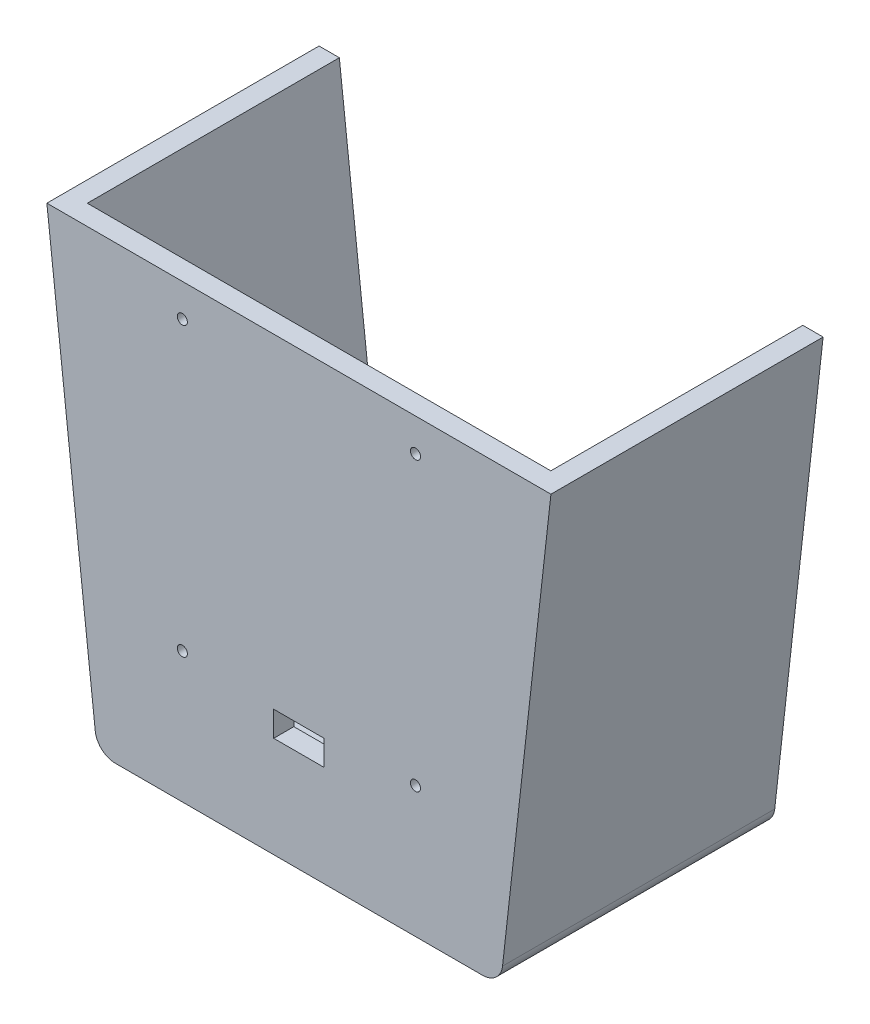
from build123d import *

# Parameters (mm, degrees)
SKETCH1_W           = 12.7
SKETCH1_H           = 6.35
BOSS_EXTRUDE1_DEPTH = 5.08
BOSS_EXTRUDE2_DEPTH = 63.5
BOSS_EXTRUDE3_DEPTH = 10.16
CUT_EXTRUDE1_DEPTH  = 7.62
SKETCH9_R           = 1.27
CUT_EXTRUDE2_DEPTH  = 5.08


with BuildPart() as part:
    # Sketch1 → Boss-Extrude1 (new body)
    with BuildSketch(Plane.XY):
        with BuildLine():
            Line((63.5, 56.7961272), (-63.5, 56.7961272))
            Line((-63.5, 56.7961272), (-51.304854459, -52.280570501))
            ThreePointArc((-51.304854459, -52.280570501), (-49.642976536, -55.502534499), (-46.25630987, -56.796126057))
            Line((-46.25630987, -56.796126057), (46.25630987, -56.796126057))
            ThreePointArc((46.25630987, -56.796126057), (49.642976536, -55.502534499), (51.304854459, -52.280570501))
            Line((51.304854459, -52.280570501), (63.5, 56.7961272))
        make_face()
        with Locations((0, -28.221126057)):
            Rectangle(SKETCH1_W, SKETCH1_H, mode=Mode.SUBTRACT)
    extrude(amount=-BOSS_EXTRUDE1_DEPTH)

    # Sketch2 → Boss-Extrude2 (add)
    with BuildSketch(Plane.XY.offset(-5.08)):
        with BuildLine():
            Line((51.304854459, -52.280570501), (63.5, 56.7961272))
            Line((63.5, 56.7961272), (58.388348603, 56.7961272))
            Line((58.388348603, 56.7961272), (46.761164329, -47.200570501))
            ThreePointArc((46.761164329, -47.200570501), (45.099286406, -50.422534499), (41.712619739, -51.716126057))
            Line((41.712619739, -51.716126057), (-41.712619739, -51.716126057))
            ThreePointArc((-41.712619739, -51.716126057), (-45.099286406, -50.422534499), (-46.761164329, -47.200570501))
            Line((-46.761164329, -47.200570501), (-58.388348603, 56.7961272))
            Line((-58.388348603, 56.7961272), (-63.5, 56.7961272))
            Line((-63.5, 56.7961272), (-51.304854459, -52.280570501))
            ThreePointArc((-51.304854459, -52.280570501), (-49.642976536, -55.502534499), (-46.25630987, -56.796126057))
            Line((-46.25630987, -56.796126057), (46.25630987, -56.796126057))
            ThreePointArc((46.25630987, -56.796126057), (49.642976536, -55.502534499), (51.304854459, -52.280570501))
        make_face()
    extrude(amount=-BOSS_EXTRUDE2_DEPTH)

    # Sketch4 → Boss-Extrude3 (add)
    with BuildSketch(Plane(origin=(0, 0, -5.08), x_dir=(-1, 0, 0), z_dir=(0, 0, -1))):
        Polygon((-20.319997003, 44.0961272), (-20.319997003, -19.4038728), (20.320002997, -19.4038728), align=None)
    extrude(amount=BOSS_EXTRUDE3_DEPTH)

    # Sketch7 → Cut-Extrude1 (cut)
    with BuildSketch(Plane(origin=(0, 0, -12.7), x_dir=(-1, 0, 0), z_dir=(0, 0, -1))):
        Polygon((18.694402997, -16.8638728), (-17.779997003, -16.8638728), (-17.779997003, 40.1273772), align=None)
    extrude(amount=-CUT_EXTRUDE1_DEPTH, mode=Mode.SUBTRACT)

    # Sketch9 → Cut-Extrude2 (cut)
    with BuildSketch(Plane.XY):
        with Locations((29.36937484, 48.5411272)):
            Circle(SKETCH9_R)
        with Locations((-29.36937484, 48.5411272)):
            Circle(SKETCH9_R)
        with Locations((29.36937484, -23.848871657)):
            Circle(SKETCH9_R)
        with Locations((-29.36937484, -23.848871657)):
            Circle(SKETCH9_R)
    extrude(amount=-CUT_EXTRUDE2_DEPTH, mode=Mode.SUBTRACT)


solid = part.part
